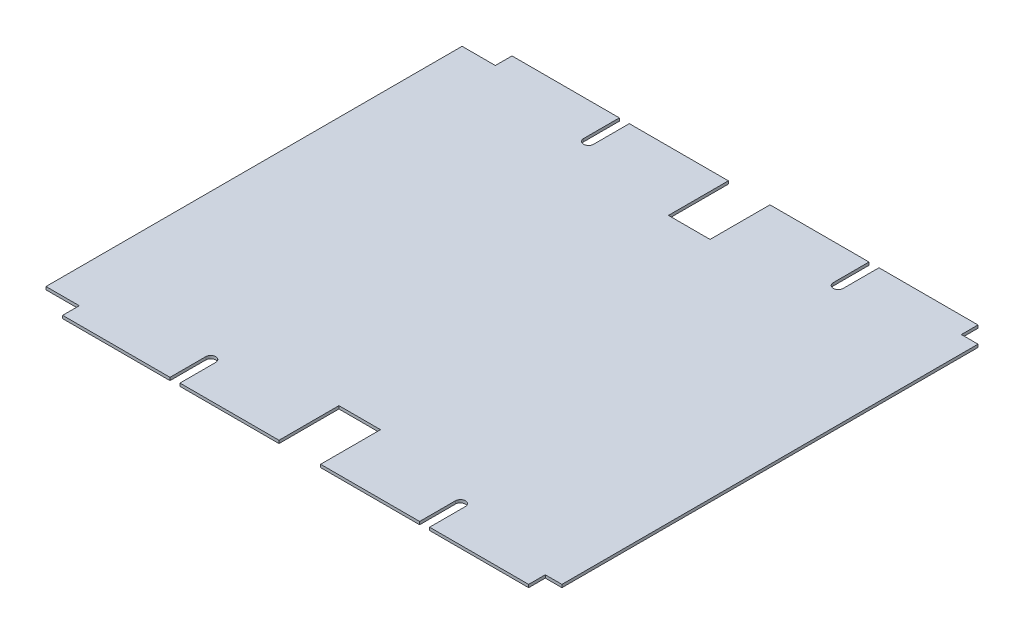
from build123d import *

# Parameters (mm, degrees)
BOSS_EXTRUDE1_DEPTH = 3.5
SKETCH2_W           = 20
SKETCH2_H           = 40
CUT_EXTRUDE1_DEPTH  = 10
CUT_EXTRUDE2_DEPTH  = 10
SKETCH4_W           = 20
SKETCH4_H           = 420
CUT_EXTRUDE3_DEPTH  = 4.5


with BuildPart() as part:
    # Sketch1 → Boss-Extrude1 (new body)
    with BuildSketch(Plane(origin=(0, 0, 0), x_dir=(1, 0, 0), z_dir=(0, 1, 0))):
        Polygon((-280, 270), (280, 270), (280, 250), (320, 250), (320, -250), (280, -250), (280, -270), (-280, -270), (-280, -250), (-320, -250), (-320, 250), (-280, 250), align=None)
    extrude(amount=BOSS_EXTRUDE1_DEPTH)

    # Sketch2 → Cut-Extrude1 (cut)
    with BuildSketch(Plane(origin=(0, 3.5, 0), x_dir=(1, 0, 0), z_dir=(0, 1, 0))):
        Polygon((30, -250), (30, -198), (-20, -198), (-20, -250), (-20, -270), (30, -270), align=None)
        Polygon((-20, 198), (30, 198), (30, 250), (30, 270), (-20, 270), (-20, 250), align=None)
        with Locations((310, 230)):
            Rectangle(SKETCH2_W, SKETCH2_H)
        with Locations((310, -230)):
            Rectangle(SKETCH2_W, SKETCH2_H)
    extrude(amount=-CUT_EXTRUDE1_DEPTH, mode=Mode.SUBTRACT)

    # Sketch3 → Cut-Extrude2 (cut)
    with BuildSketch(Plane(origin=(0, 3.5, 0), x_dir=(1, 0, 0), z_dir=(0, 1, 0))):
        with BuildLine():
            Line((149, 227), (149, 270))
            Line((149, 270), (161, 270))
            Line((161, 270), (161, 227))
            ThreePointArc((161, 227), (155, 221), (149, 227))
        make_face()
        with BuildLine():
            Line((161, -227), (161, -270))
            Line((161, -270), (149, -270))
            Line((149, -270), (149, -227))
            ThreePointArc((149, -227), (155, -221), (161, -227))
        make_face()
        with BuildLine():
            Line((-139, -227), (-139, -270))
            Line((-139, -270), (-151, -270))
            Line((-151, -270), (-151, -227))
            ThreePointArc((-151, -227), (-145, -221), (-139, -227))
        make_face()
        with BuildLine():
            Line((-151, 227), (-151, 270))
            Line((-151, 270), (-139, 270))
            Line((-139, 270), (-139, 227))
            ThreePointArc((-139, 227), (-145, 221), (-151, 227))
        make_face()
    extrude(amount=-CUT_EXTRUDE2_DEPTH, mode=Mode.SUBTRACT)

    # Sketch4 → Cut-Extrude3 (cut, through all)
    with BuildSketch(Plane(origin=(0, 3.5, 0), x_dir=(1, 0, 0), z_dir=(0, 1, 0))):
        with Locations((310, 0)):
            Rectangle(SKETCH4_W, SKETCH4_H)
    extrude(amount=-CUT_EXTRUDE3_DEPTH, mode=Mode.SUBTRACT)


solid = part.part
